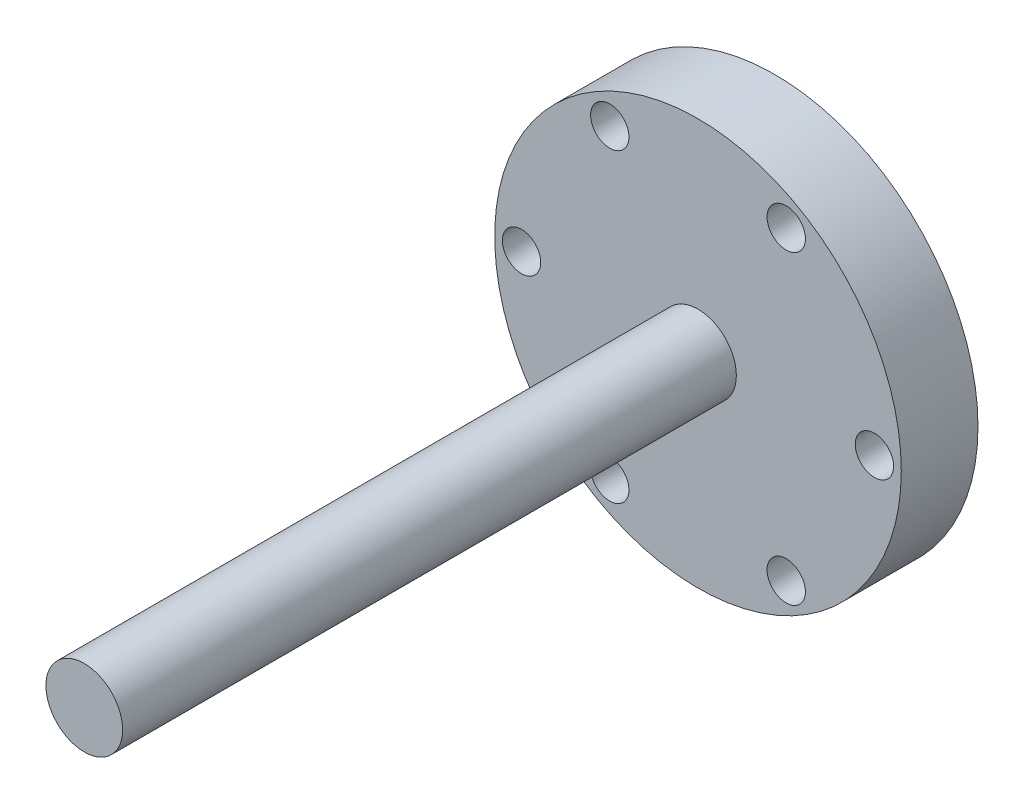
from build123d import *

# Parameters (mm, degrees)
SKETCH1_R           = 26.5
SKETCH1_R_2         = 2.5
BOSS_EXTRUDE1_DEPTH = 10
SKETCH2_R           = 5
BOSS_EXTRUDE2_DEPTH = 80


with BuildPart() as part:
    # Sketch1 → Boss-Extrude1 (new body)
    with BuildSketch(Plane.XY):
        Circle(SKETCH1_R)
        with Locations((23, 0)):
            Circle(SKETCH1_R_2, mode=Mode.SUBTRACT)
        with Locations((11.5, 19.918584287)):
            Circle(SKETCH1_R_2, mode=Mode.SUBTRACT)
        with Locations((-11.5, 19.918584287)):
            Circle(SKETCH1_R_2, mode=Mode.SUBTRACT)
        with Locations((-23, 0)):
            Circle(SKETCH1_R_2, mode=Mode.SUBTRACT)
        with Locations((-11.5, -19.918584287)):
            Circle(SKETCH1_R_2, mode=Mode.SUBTRACT)
        with Locations((11.5, -19.918584287)):
            Circle(SKETCH1_R_2, mode=Mode.SUBTRACT)
    extrude(amount=BOSS_EXTRUDE1_DEPTH)

    # Sketch2 → Boss-Extrude2 (add)
    with BuildSketch(Plane.XY.offset(10)):
        Circle(SKETCH2_R)
    extrude(amount=BOSS_EXTRUDE2_DEPTH)


solid = part.part
